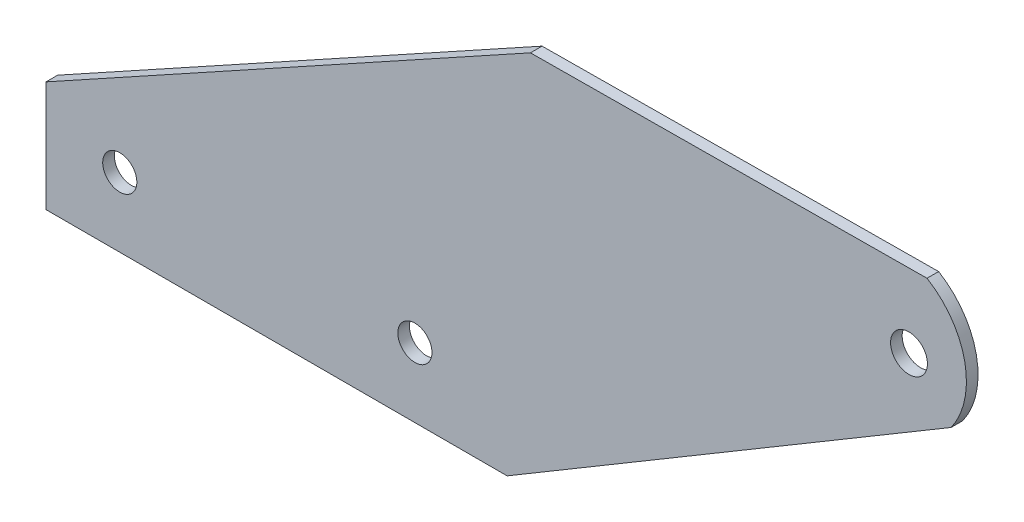
from build123d import *

# Parameters (mm, degrees)
SKETCH1_R           = 2.3495
SKETCH1_R_2         = 2.54
BOSS_EXTRUDE1_DEPTH = 1.6002


with BuildPart() as part:
    # Sketch1 → Boss-Extrude1 (new body)
    with BuildSketch(Plane.XY):
        with BuildLine():
            Line((0, 0), (0, 15.24))
            Line((0, 15.24), (66.713584346, 52.060343069))
            Line((66.713584346, 52.060343069), (121.323584346, 52.482745441))
            ThreePointArc((121.323584346, 52.482745441), (126.52255489, 45.138126941), (124.63483314, 36.339875852))
            Line((124.63483314, 36.339875852), (63.5, 0))
            Line((63.5, 0), (0, 0))
        make_face()
        with Locations((10.16, 9.525)):
            Circle(SKETCH1_R, mode=Mode.SUBTRACT)
        with Locations((50.8, 9.525)):
            Circle(SKETCH1_R, mode=Mode.SUBTRACT)
        with Locations((118.841606936, 42.303243693)):
            Circle(SKETCH1_R_2, mode=Mode.SUBTRACT)
    extrude(amount=-BOSS_EXTRUDE1_DEPTH)


solid = part.part
